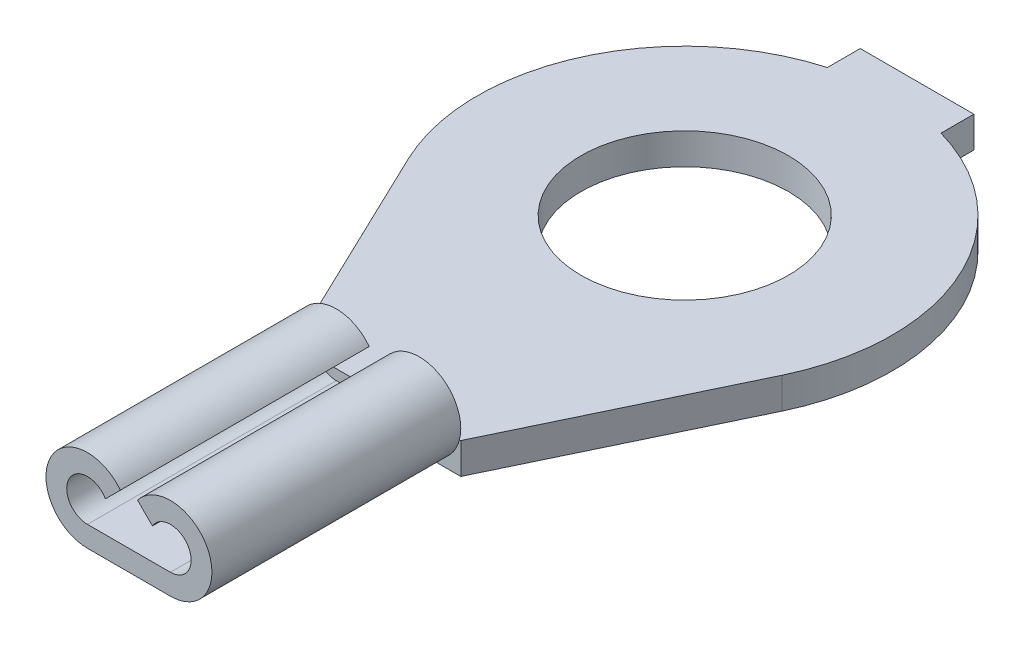
from build123d import *

# Parameters (mm, degrees)
SKETCH1_R           = 1.27
BOSS_EXTRUDE1_DEPTH = 0.381
SKETCH2_W           = 2.032
SKETCH2_H           = 3.048
BOSS_EXTRUDE2_DEPTH = 0.635
CUT_EXTRUDE1_START  = -3.048
CUT_EXTRUDE1_DEPTH  = 3.048


with BuildPart() as part:
    # Sketch1 → Boss-Extrude1 (new body)
    with BuildSketch(Plane(origin=(0, 0, 0), x_dir=(1, 0, 0), z_dir=(0, 1, 0))):
        with BuildLine():
            Line((-0.695956456, 2.442794427), (-0.695956456, 2.845479033))
            Line((-0.695956456, 2.845479033), (0.695956456, 2.845479033))
            Line((0.695956456, 2.845479033), (0.695956456, 2.442794427))
            ThreePointArc((0.695956456, 2.442794427), (2.315850071, 1.043282535), (2.290753246, -1.097291924))
            Line((2.290753246, -1.097291924), (1.016, -3.758520967))
            Line((1.016, -3.758520967), (1.016, -6.806520967))
            Line((1.016, -6.806520967), (-1.016, -6.806520967))
            Line((-1.016, -6.806520967), (-1.016, -3.758520967))
            Line((-1.016, -3.758520967), (-2.290753246, -1.097291924))
            ThreePointArc((-2.290753246, -1.097291924), (-2.315850071, 1.043282535), (-0.695956456, 2.442794427))
        make_face()
        Circle(SKETCH1_R, mode=Mode.SUBTRACT)
    extrude(amount=BOSS_EXTRUDE1_DEPTH)

    # Sketch2 → Boss-Extrude2 (add)
    with BuildSketch(Plane(origin=(0, 0.381, 0), x_dir=(1, 0, 0), z_dir=(0, 1, 0))):
        with Locations((0, -5.282520967)):
            Rectangle(SKETCH2_W, SKETCH2_H)
    extrude(amount=BOSS_EXTRUDE2_DEPTH)

    # Sketch3 → Cut-Extrude1 (cut)
    with BuildSketch(Plane.XY.offset(6.806520967).offset(CUT_EXTRUDE1_START)):
        with BuildLine():
            ThreePointArc((1.016, 0.508), (0.867210245, 0.148789755), (0.508, 0))
            Line((0.508, 0), (1.016, 0))
            Line((1.016, 0), (1.016, 0.508))
        make_face()
        with BuildLine():
            ThreePointArc((-0.508, 0), (-0.867210245, 0.148789755), (-1.016, 0.508))
            Line((-1.016, 0.508), (-1.016, 0))
            Line((-1.016, 0), (-0.508, 0))
        make_face()
        with BuildLine():
            ThreePointArc((-1.016, 0.508), (-0.867210245, 0.867210245), (-0.508, 1.016))
            Line((-0.508, 1.016), (-1.016, 1.016))
            Line((-1.016, 1.016), (-1.016, 0.508))
        make_face()
        with BuildLine():
            ThreePointArc((0.105325044, 0.817704504), (0.283573941, 0.963737802), (0.508, 1.016))
            Line((0.508, 1.016), (-0.508, 1.016))
            ThreePointArc((-0.508, 1.016), (-0.283573941, 0.963737802), (-0.105325044, 0.817704504))
            Line((-0.105325044, 0.817704504), (-0.288029547, 0.635))
            ThreePointArc((-0.288029547, 0.635), (-0.727970453, 0.635), (-0.508, 0.254))
            Line((-0.508, 0.254), (0.508, 0.254))
            ThreePointArc((0.508, 0.254), (0.727970453, 0.635), (0.288029547, 0.635))
            Line((0.288029547, 0.635), (0.105325044, 0.817704504))
        make_face()
        with BuildLine():
            ThreePointArc((0.508, 1.016), (0.867210245, 0.867210245), (1.016, 0.508))
            Line((1.016, 0.508), (1.016, 1.016))
            Line((1.016, 1.016), (0.508, 1.016))
        make_face()
    extrude(amount=CUT_EXTRUDE1_DEPTH, mode=Mode.SUBTRACT)


solid = part.part
